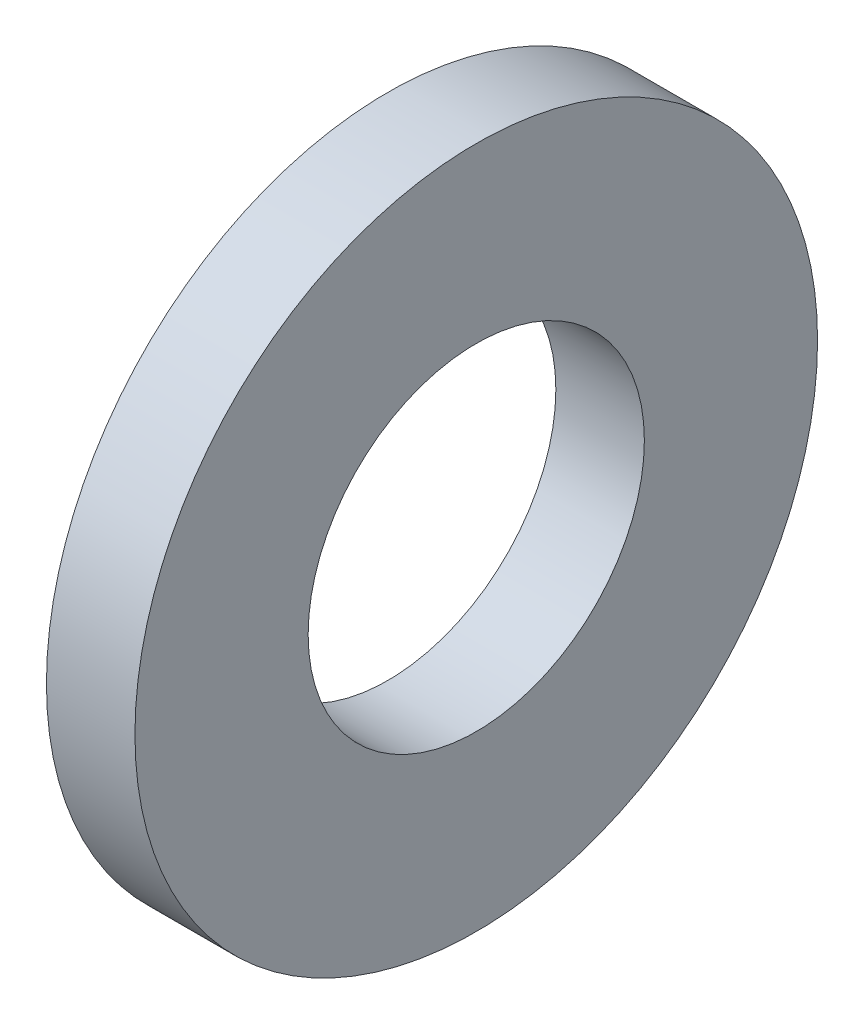
from build123d import *

# Parameters (mm, degrees)
SKETCH1_R           = 17.0434
SKETCH1_R_2         = 8.3947
BOSS_EXTRUDE1_DEPTH = 4.4196


with BuildPart() as part:
    # Sketch1 → Boss-Extrude1 (new body)
    with BuildSketch(Plane(origin=(0, 0, 0), x_dir=(0, 0, -1), z_dir=(1, 0, 0))):
        Circle(SKETCH1_R)
        Circle(SKETCH1_R_2, mode=Mode.SUBTRACT)
    extrude(amount=BOSS_EXTRUDE1_DEPTH)


solid = part.part
